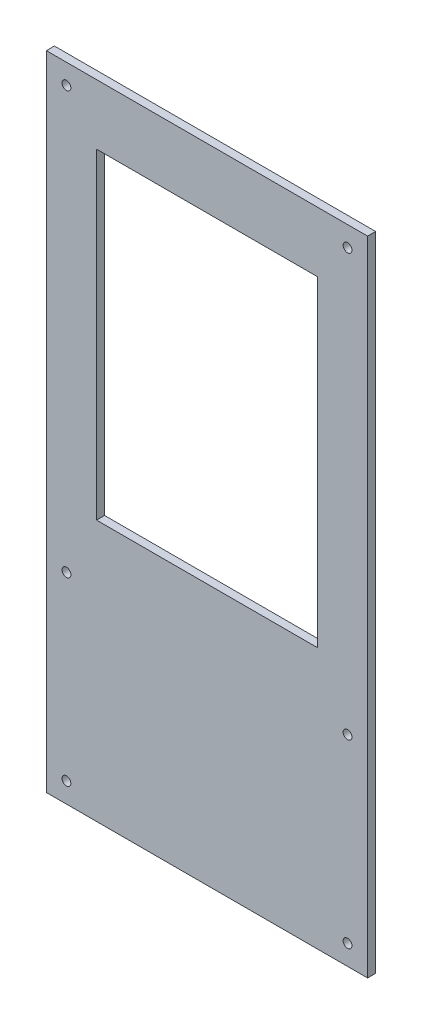
from build123d import *

# Parameters (mm, degrees)
ESQUISSE1_W             = 160
ESQUISSE1_H             = 440
ESQUISSE1_R             = 2.2
ESQUISSE1_W_2           = 110
ESQUISSE1_H_2           = 160
BOSS_EXTRU_1_DEPTH      = 4
ESQUISSE2_R             = 2.2
ESQUISSE2_W             = 160
ESQUISSE2_H             = 120
ENL_V_MAT_EXTRU_1_DEPTH = 5


with BuildPart() as part:
    # Esquisse1 → Boss.-Extru.1 (new body)
    with BuildSketch(Plane.XY):
        Rectangle(ESQUISSE1_W, ESQUISSE1_H)
        with Locations((70, 0)):
            Circle(ESQUISSE1_R, mode=Mode.SUBTRACT)
        with Locations((70, 210)):
            Circle(ESQUISSE1_R, mode=Mode.SUBTRACT)
        with Locations((70, -210)):
            Circle(ESQUISSE1_R, mode=Mode.SUBTRACT)
        with Locations((-70, 210)):
            Circle(ESQUISSE1_R, mode=Mode.SUBTRACT)
        with Locations((-70, 0)):
            Circle(ESQUISSE1_R, mode=Mode.SUBTRACT)
        with Locations((-70, -210)):
            Circle(ESQUISSE1_R, mode=Mode.SUBTRACT)
        with Locations((0, 110)):
            Rectangle(ESQUISSE1_W_2, ESQUISSE1_H_2, mode=Mode.SUBTRACT)
    extrude(amount=BOSS_EXTRU_1_DEPTH)

    # Esquisse2 → Enlèv. mat.-Extru.1 (cut, through all)
    with BuildSketch(Plane.XY.offset(4)):
        with Locations((-70, -90)):
            Circle(ESQUISSE2_R)
        with Locations((70, -90)):
            Circle(ESQUISSE2_R)
        with Locations((0, -160)):
            Rectangle(ESQUISSE2_W, ESQUISSE2_H)
    extrude(amount=-ENL_V_MAT_EXTRU_1_DEPTH, mode=Mode.SUBTRACT)


solid = part.part
